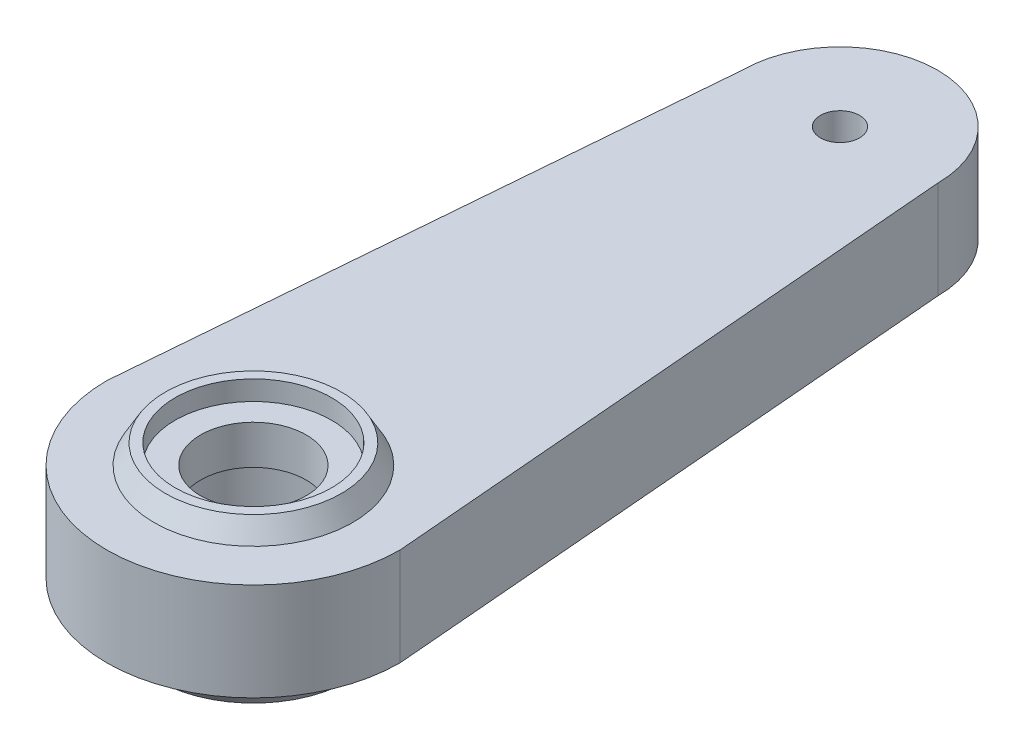
from build123d import *

# Parameters (mm, degrees)
BOSS_EXTRUDE1_DEPTH = 5
SKETCH2_R           = 4
SKETCH2_R_2         = 1
CUT_EXTRUDE1_DEPTH  = 5
SKETCH3_R           = 5
BOSS_EXTRUDE3_DEPTH = 2
DRAFT3_ANGLE        = 30
SKETCH4_R           = 4
CUT_EXTRUDE2_DEPTH  = 2
SKETCH5_R           = 4
SKETCH5_R_2         = 2.700917016
BOSS_EXTRUDE4_DEPTH = 2
SKETCH6_R           = 4.5
SKETCH6_R_2         = 4
BOSS_EXTRUDE5_DEPTH = 1
DRAFT4_ANGLE        = 30


with BuildPart() as part:
    # Sketch1 → Boss-Extrude1 (new body)
    with BuildSketch(Plane(origin=(0, 0, 0), x_dir=(1, 0, 0), z_dir=(0, 1, 0))):
        with BuildLine():
            Line((-7.5, 0), (-5, 30))
            ThreePointArc((-5, 30), (0, 35), (5, 30))
            Line((5, 30), (7.5, 0))
            ThreePointArc((7.5, 0), (0, -7.5), (-7.5, 0))
        make_face()
    extrude(amount=BOSS_EXTRUDE1_DEPTH)

    # Sketch2 → Cut-Extrude1 (cut)
    with BuildSketch(Plane(origin=(0, 5, 0), x_dir=(1, 0, 0), z_dir=(0, 1, 0))):
        Circle(SKETCH2_R)
        with Locations((0, 30)):
            Circle(SKETCH2_R_2)
    extrude(amount=-CUT_EXTRUDE1_DEPTH, mode=Mode.SUBTRACT)

    # Sketch3 → Boss-Extrude3 (add)
    with BuildSketch(Plane.XZ):
        Circle(SKETCH3_R)
    extrude(amount=BOSS_EXTRUDE3_DEPTH)

    # Draft3
    draft3_faces = [part.faces().sort_by_distance(p)[0] for p in [
        (-5, -1, 0),
    ]]
    draft(draft3_faces, Plane(origin=(0, -2, 0), x_dir=(0, 0, -1), z_dir=(0, -1, 0)), DRAFT3_ANGLE)

    # Sketch4 → Cut-Extrude2 (cut)
    with BuildSketch(Plane(origin=(0, 0, 0), x_dir=(1, 0, 0), z_dir=(0, 1, 0))):
        Circle(SKETCH4_R)
    extrude(amount=-CUT_EXTRUDE2_DEPTH, mode=Mode.SUBTRACT)

    # Sketch5 → Boss-Extrude4 (add)
    with BuildSketch(Plane(origin=(0, 5, 0), x_dir=(1, 0, 0), z_dir=(0, 1, 0))):
        Circle(SKETCH5_R)
        Circle(SKETCH5_R_2, mode=Mode.SUBTRACT)
    extrude(amount=-BOSS_EXTRUDE4_DEPTH)

    # Sketch6 → Boss-Extrude5 (add)
    with BuildSketch(Plane(origin=(0, 5, 0), x_dir=(1, 0, 0), z_dir=(0, 1, 0))):
        Circle(SKETCH6_R)
        Circle(SKETCH6_R_2, mode=Mode.SUBTRACT)
    extrude(amount=BOSS_EXTRUDE5_DEPTH)

    # Draft4
    draft4_faces = [part.faces().sort_by_distance(p)[0] for p in [
        (-4.5, 5.5, 0),
    ]]
    draft(draft4_faces, Plane.ZX.offset(6), DRAFT4_ANGLE)


solid = part.part
